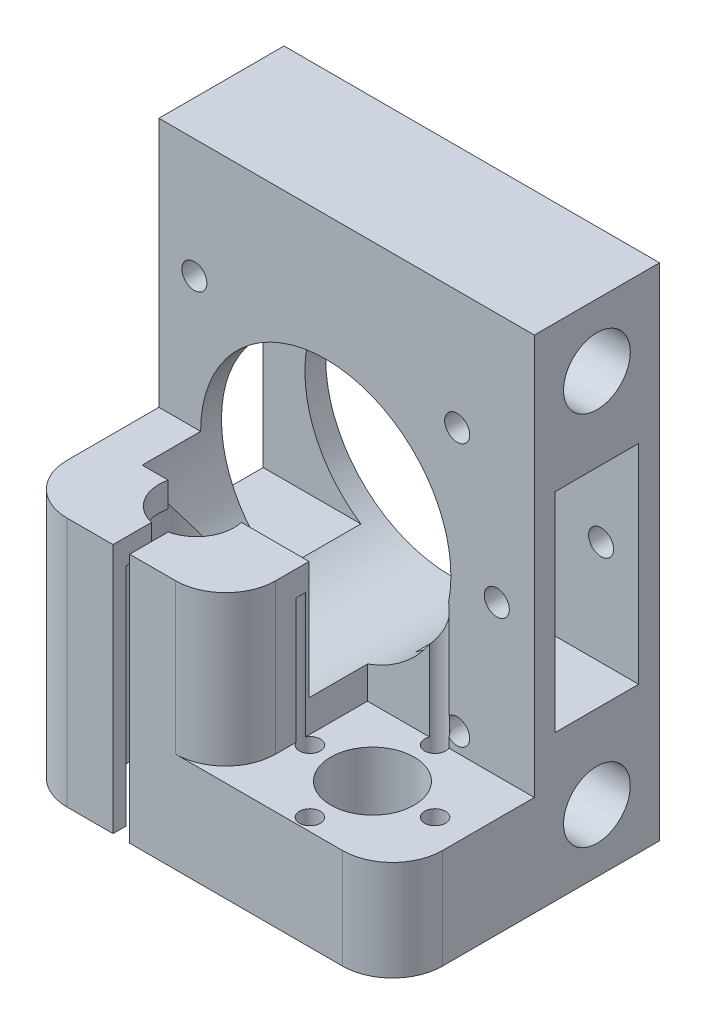
from build123d import *

# Parameters (mm, degrees)
SKETCH1_W           = 45
SKETCH1_H           = 60
BOSS_EXTRUDE1_DEPTH = 15
SKETCH2_R           = 4
SKETCH2_W           = 10
SKETCH2_H           = 25
CUT_EXTRUDE1_DEPTH  = 46
SKETCH3_W           = 17
SKETCH3_H           = 12
BOSS_EXTRUDE2_DEPTH = 45
SKETCH4_W           = 25
SKETCH4_H           = 17
BOSS_EXTRUDE3_DEPTH = 18
SKETCH5_W           = 2
SKETCH5_H           = 30
CUT_EXTRUDE2_DEPTH  = 5
SKETCH6_R           = 4.5
CUT_EXTRUDE3_DEPTH  = 61
SKETCH7_R           = 7.5
SKETCH7_R_2         = 5
SKETCH7_R_3         = 1.25
CUT_EXTRUDE4_DEPTH  = 27
SKETCH8_R           = 15
SKETCH8_R_2         = 1.5
CUT_EXTRUDE5_DEPTH  = 22
FILLET1_R           = 6
SKETCH9_R           = 1.5
CUT_EXTRUDE6_DEPTH  = 15


with BuildPart() as part:
    # Sketch1 → Boss-Extrude1 (new body)
    with BuildSketch(Plane.XY):
        Rectangle(SKETCH1_W, SKETCH1_H)
    extrude(amount=BOSS_EXTRUDE1_DEPTH)

    # Sketch2 → Cut-Extrude1 (cut, through all)
    with BuildSketch(Plane(origin=(22.5, 0, 0), x_dir=(0, 0, -1), z_dir=(1, 0, 0))):
        with Locations((-7.5, 22.5)):
            Circle(SKETCH2_R)
        with Locations((-7.5, -22.5)):
            Circle(SKETCH2_R)
        with Locations((-7.5, 0)):
            Rectangle(SKETCH2_W, SKETCH2_H)
    extrude(amount=-CUT_EXTRUDE1_DEPTH, mode=Mode.SUBTRACT)

    # Sketch3 → Boss-Extrude2 (add)
    with BuildSketch(Plane.ZY.offset(22.5)):
        with Locations((23.5, -24)):
            Rectangle(SKETCH3_W, SKETCH3_H)
    extrude(amount=-BOSS_EXTRUDE2_DEPTH)

    # Sketch4 → Boss-Extrude3 (add)
    with BuildSketch(Plane(origin=(0, -18, 0), x_dir=(1, 0, 0), z_dir=(0, 1, 0))):
        with Locations((-10, -23.5)):
            Rectangle(SKETCH4_W, SKETCH4_H)
    extrude(amount=BOSS_EXTRUDE3_DEPTH)

    # Sketch5 → Cut-Extrude2 (cut)
    with BuildSketch(Plane.XY.offset(32)):
        with Locations((-10, -15)):
            Rectangle(SKETCH5_W, SKETCH5_H)
    extrude(amount=-CUT_EXTRUDE2_DEPTH, mode=Mode.SUBTRACT)

    # Sketch6 → Cut-Extrude3 (cut, through all)
    with BuildSketch(Plane.XZ.offset(30)):
        with Locations((-10, 23)):
            Circle(SKETCH6_R)
    extrude(amount=-CUT_EXTRUDE3_DEPTH, mode=Mode.SUBTRACT)

    # Sketch7 → Cut-Extrude4 (cut)
    with BuildSketch(Plane.XZ.offset(30)):
        with Locations((-10, 23)):
            Circle(SKETCH7_R)
        with Locations((11.1, 23)):
            Circle(SKETCH7_R_2)
        with Locations((18.6, 23)):
            Circle(SKETCH7_R_3)
        with Locations((11.1, 30.5)):
            Circle(SKETCH7_R_3)
        with Locations((11.1, 15.5)):
            Circle(SKETCH7_R_3)
        with Locations((3.6, 23)):
            Circle(SKETCH7_R_3)
    extrude(amount=-CUT_EXTRUDE4_DEPTH, mode=Mode.SUBTRACT)

    # Sketch8 → Cut-Extrude5 (cut)
    with BuildSketch(Plane(origin=(0, 0, 0), x_dir=(-1, 0, 0), z_dir=(0, 0, -1))):
        with Locations((2.5, 0)):
            Circle(SKETCH8_R)
        with Locations((18.25, 15.75)):
            Circle(SKETCH8_R_2)
        with Locations((-13.25, 15.75)):
            Circle(SKETCH8_R_2)
        with Locations((-13.25, -15.75)):
            Circle(SKETCH8_R_2)
        with Locations((18.25, -15.75)):
            Circle(SKETCH8_R_2)
    extrude(amount=-CUT_EXTRUDE5_DEPTH, mode=Mode.SUBTRACT)

    # Fillet1
    fillet1_edges = [part.edges().sort_by_distance(p)[0] for p in [
        (-22.5, -15, 32),
        (22.5, -24, 32),
        (2.5, -9, 32),
    ]]
    fillet(fillet1_edges, radius=FILLET1_R)

    # Sketch9 → Cut-Extrude6 (cut)
    with BuildSketch(Plane(origin=(0, 0, 0), x_dir=(-1, 0, 0), z_dir=(0, 0, -1))):
        with Locations((-18, 0)):
            Circle(SKETCH9_R)
    extrude(amount=-CUT_EXTRUDE6_DEPTH, mode=Mode.SUBTRACT)


solid = part.part
